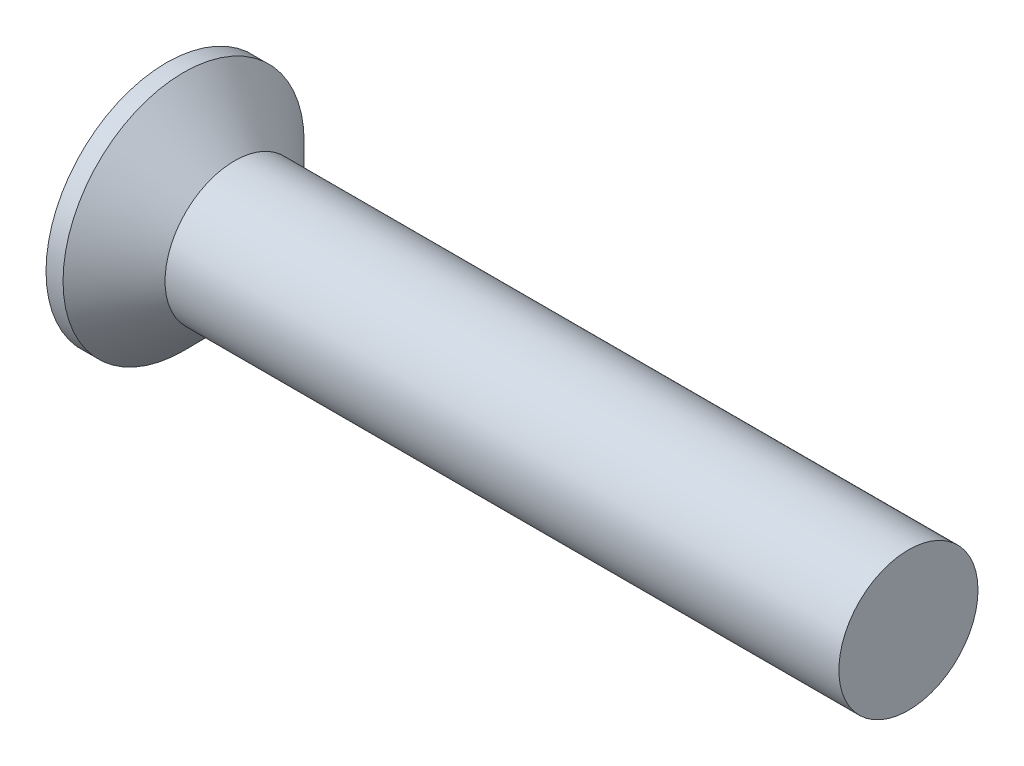
from build123d import *

# Parameters (mm, degrees)
BASETOP_FACE_RADIUS = 2.6
BASETOP_HEIGHT      = 0.7
CROSSRECESS_DEPTH   = 0.825
DRAFT9_ANGLE        = -30
FILLET5_R           = 0.3


with BuildPart() as part:
    # Sketch1 → Base (revolve)
    with BuildSketch(Plane.XY):
        Polygon((16, 1.5), (2.737867966, 1.5), (1.467367966, 1.5), (0.367367966, 2.6), (0, 2.6), (0, 0), (16, 0), align=None)
    revolve(axis=Axis((4.515812911, 0, 0), (-1, 0, 0)))

    # BaseTop: a dome of height H over a round flat face of radius A is a cap of a sphere of radius (A * A + H * H) / (2 * H)
    basetop_r = (BASETOP_FACE_RADIUS * BASETOP_FACE_RADIUS + BASETOP_HEIGHT * BASETOP_HEIGHT) / (2 * BASETOP_HEIGHT)
    basetop_base = Plane((0, 0, 0), z_dir=(-1, 0, 0))
    with Locations(basetop_base.offset(BASETOP_HEIGHT - basetop_r)):
        basetop_ball = Sphere(basetop_r, mode=Mode.PRIVATE)
    add(split(basetop_ball, bisect_by=basetop_base, keep=Keep.TOP, mode=Mode.PRIVATE))

    # Sketch6 → CrossRecess (cut)
    with BuildSketch(Plane.ZY.offset(0.7)):
        Polygon((0.34, 0.34), (0.34, 1.7), (-0.34, 1.7), (-0.34, 0.34), (-1.7, 0.34), (-1.7, -0.34), (-0.34, -0.34), (-0.34, -1.7), (0.34, -1.7), (0.34, -0.34), (1.7, -0.34), (1.7, 0.34), align=None)
    extrude(amount=-CROSSRECESS_DEPTH, mode=Mode.SUBTRACT)

    # Draft9
    draft9_faces = [part.faces().sort_by_distance(p)[0] for p in [
        (-0.14204754, 0, -1.7),
        (-0.14204754, -1.7, 0),
        (-0.14204754, 0, 1.7),
        (-0.14204754, 1.7, 0),
    ]]
    draft(draft9_faces, Plane(origin=(-0.7, 0, 0), x_dir=(0, 0, 1), z_dir=(1, 0, 0)), DRAFT9_ANGLE)

    # Fillet5
    fillet5_edges = [part.edges().sort_by_distance(p)[0] for p in [
        (-0.27631446, 0.34, -0.34),
        (-0.27631446, 0.34, 0.34),
        (-0.27631446, -0.34, 0.34),
        (-0.27631446, -0.34, -0.34),
    ]]
    fillet(fillet5_edges, radius=FILLET5_R)


solid = part.part
